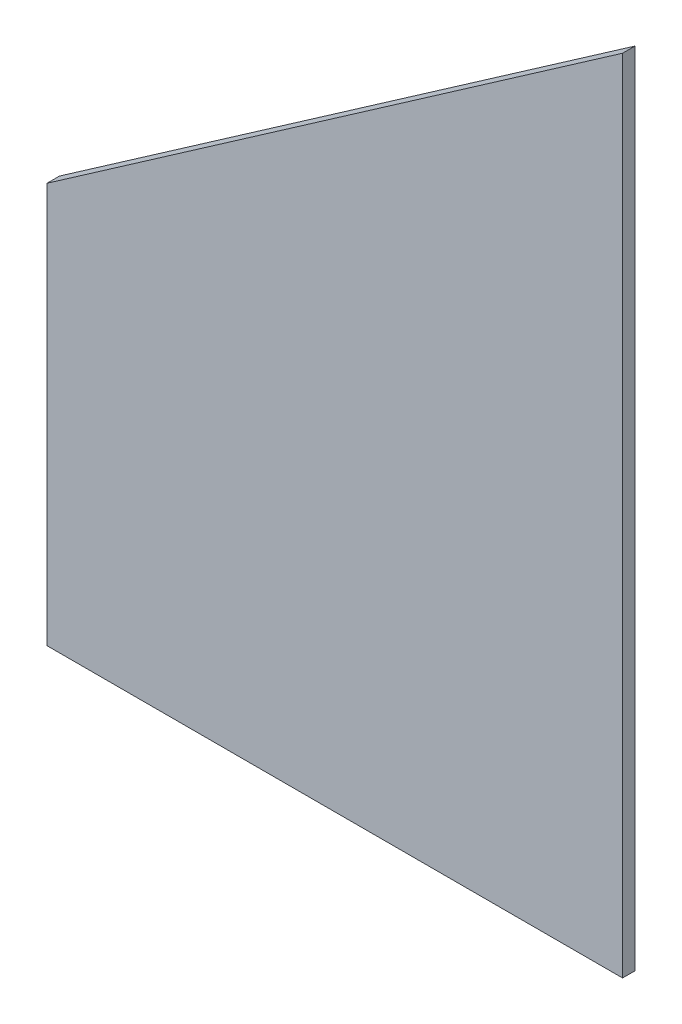
from build123d import *

# Parameters (mm, degrees)
BOSS_EXTRUDE1_DEPTH = 3.175


with BuildPart() as part:
    # Sketch1 → Boss-Extrude1 (new body)
    with BuildSketch(Plane.XY):
        Polygon((-184.15, -8.89), (-38.1, -8.89), (-38.1, 0), (-38.1, 194.31), (-184.15, 92.71), align=None)
    extrude(amount=BOSS_EXTRUDE1_DEPTH)


solid = part.part
